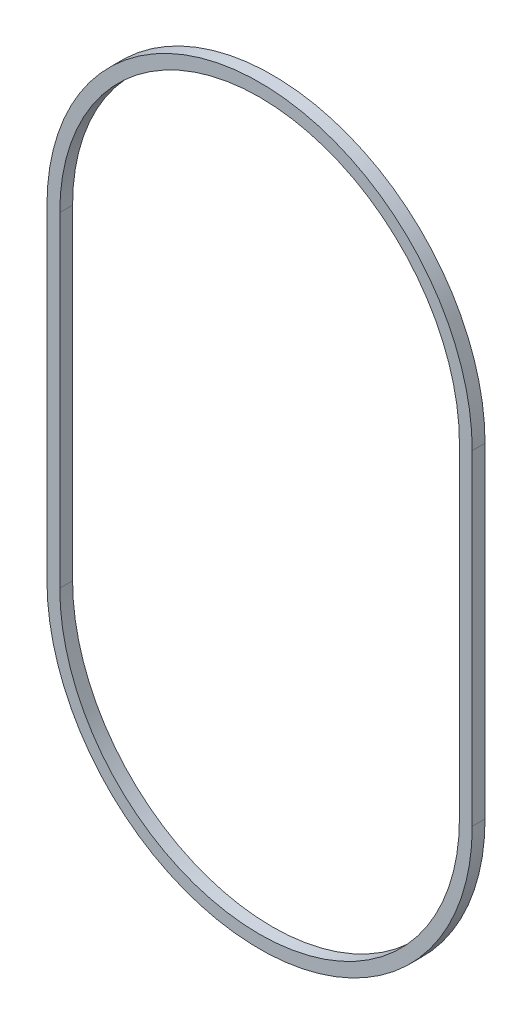
from build123d import *

# Parameters (mm, degrees)
BOSS_EXTRUDE1_DEPTH = 2.5


with BuildPart() as part:
    # Sketch1 → Boss-Extrude1 (new body)
    with BuildSketch(Plane.XY):
        with BuildLine():
            Line((41.5, 31.75), (41.5, -31.75))
            ThreePointArc((41.5, -31.75), (0, -73.25), (-41.5, -31.75))
            Line((-41.5, -31.75), (-41.5, 31.75))
            ThreePointArc((-41.5, 31.75), (0, 73.25), (41.5, 31.75))
        make_face()
        with BuildLine():
            Line((39, 31.75), (39, -31.75))
            ThreePointArc((39, -31.75), (0, -70.75), (-39, -31.75))
            Line((-39, -31.75), (-39, 31.75))
            ThreePointArc((-39, 31.75), (0, 70.75), (39, 31.75))
        make_face(mode=Mode.SUBTRACT)
    extrude(amount=BOSS_EXTRUDE1_DEPTH)


solid = part.part
